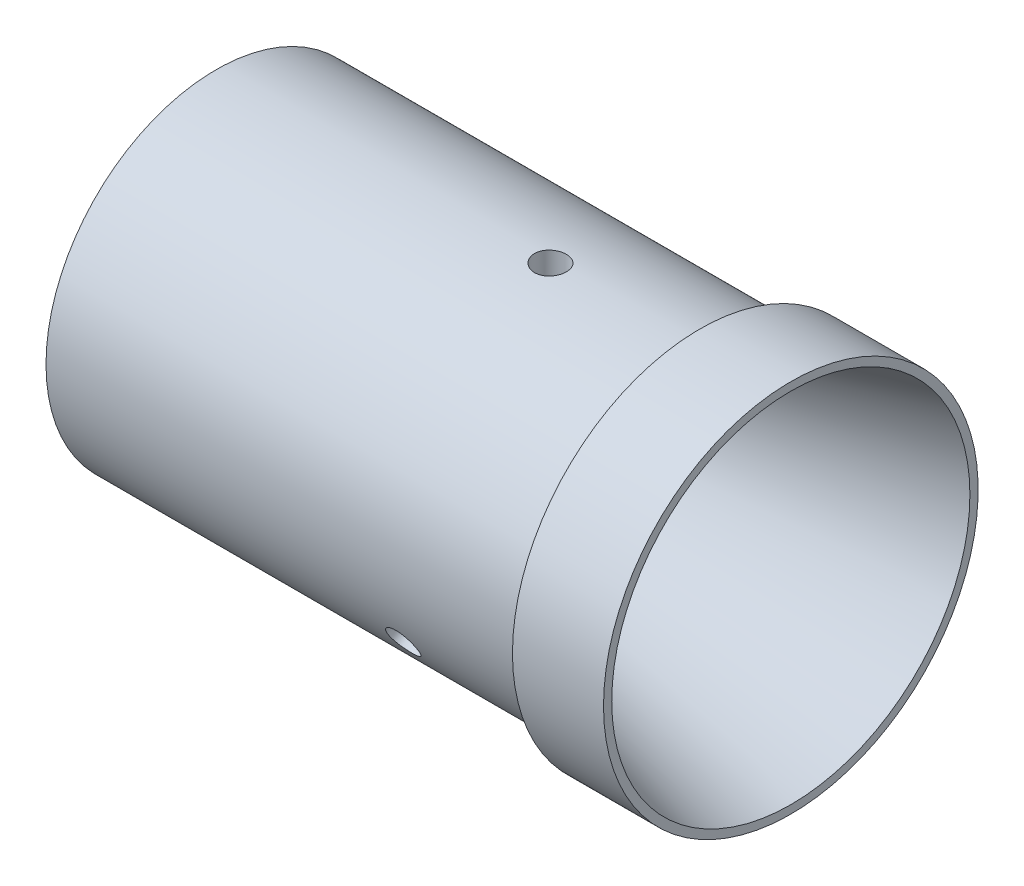
from build123d import *

# Parameters (mm, degrees)
CIRPATTERN1_COUNT = 3


with BuildPart() as part:
    # Sketch1 → Revolve1 (revolve)
    with BuildSketch(Plane.XY):
        Polygon((0, 14.478), (41.148, 14.478), (41.148, 15.9385), (48.895, 15.9385), (48.895, 15.237243561), (24.638, 8.7376), (24.638, 10.3251), (7.62, 10.3251), (7.62, 11.1633), (5.842, 11.1633), (5.842, 12.7), (0, 12.7), align=None)
    revolve(axis=Axis((0, 0, 0), (1, 0, 0)))

    # Sketch3 → #6-32 Tapped Hole1 (revolve, cut)
    with BuildSketch(Plane(origin=(28.448, 14.478, 0), x_dir=(0, 0, 1), z_dir=(1, 0, 0))):
        Polygon((0, 0), (0, 3.175), (1.35255, 2.36230597), (1.35255, 0), align=None)
    f_6_32_tapped_hole1 = revolve(axis=Axis((28.448, 20.828, 0), (0, -1, 0)), mode=Mode.SUBTRACT)

    # CirPattern1: #6-32 Tapped Hole1 ×3 about axis
    cirpattern1_axis = Axis((0, 0, 0), (-1, 0, 0))
    for i in range(1, CIRPATTERN1_COUNT):
        add(f_6_32_tapped_hole1.rotate(cirpattern1_axis, i * 360 / CIRPATTERN1_COUNT), mode=Mode.SUBTRACT)


solid = part.part
